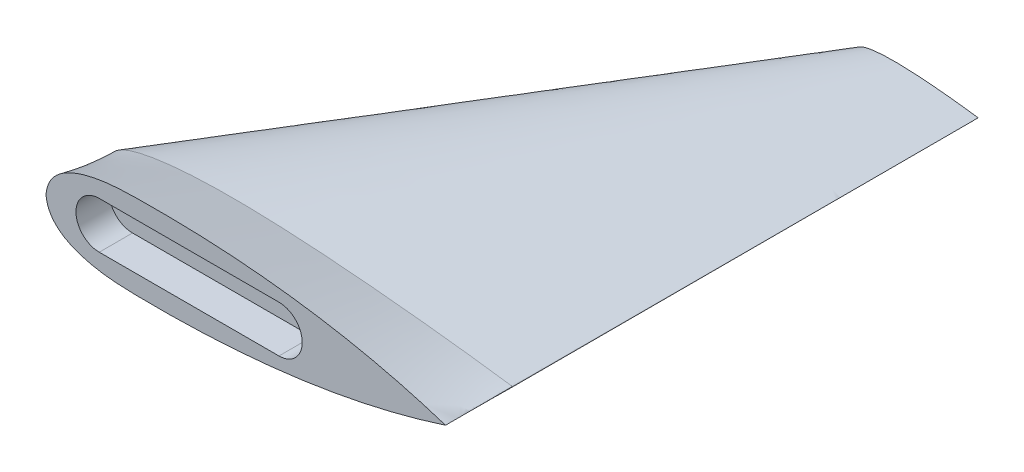
from build123d import *

# Parameters (mm, degrees)
CUT_EXTRUDE1_DEPTH = 5


with BuildPart() as part:
    # Sketch3 → Loft1 section 0
    with BuildSketch(Plane.XY.offset(70)):
        with BuildLine():
            add(Edge.make_bspline(
                [(42.022876489, 0), (42.022876489, -0.025878497), (42.030292538, -0.078965607), (42.063554444, -0.155915402), (42.117908781, -0.22997435), (42.19269573, -0.301463886), (42.287673315, -0.37063511), (42.402703243, -0.437554112), (42.537617166, -0.502144861), (42.69217588, -0.564260941), (42.866072758, -0.623717465), (43.058936641, -0.68031524), (43.270343068, -0.733841033), (43.49981216, -0.784100531), (43.74682173, -0.830887268), (44.010800762, -0.874031015), (44.291140004, -0.913354711), (44.587187402, -0.948725601), (44.898254935, -0.980017341), (45.223617257, -1.007142862), (45.562516237, -1.030039418), (45.914162375, -1.048668566), (46.27773462, -1.06303447), (46.652384122, -1.073163985), (47.037236556, -1.079112462), (47.43139403, -1.080971986), (47.833935949, -1.078853752), (48.243922409, -1.07289628), (48.660396106, -1.063260995), (49.082385456, -1.050131052), (49.508904835, -1.033698226), (49.938957981, -1.01417393), (50.371540867, -0.99177977), (50.805643888, -0.966741353), (51.240253368, -0.93929129), (51.674354334, -0.909662993), (52.106933472, -0.878089086), (52.53698035, -0.844806242), (52.963490882, -0.81003717), (53.38546826, -0.774008998), (53.801928512, -0.736940084), (54.211897782, -0.699043587), (54.614419588, -0.660532173), (55.008552494, -0.621601817), (55.393377825, -0.582454731), (55.767995156, -0.543281249), (56.131530502, -0.504273993), (56.48313406, -0.465622723), (56.821984355, -0.427500623), (57.147291331, -0.390101403), (57.458294583, -0.353598981), (57.754267715, -0.318172697), (58.034518631, -0.283997105), (58.298393967, -0.25125135), (58.54527673, -0.220100521), (58.77459078, -0.190718852), (58.9857996, -0.163257461), (59.178410588, -0.137883615), (59.351975669, -0.114738335), (59.506082658, -0.093952342), (59.640393607, -0.075694011), (59.754528952, -0.059944097), (59.848410148, -0.047189767), (59.921315664, -0.036471248), (59.974295109, -0.030390073), (60.004730475, -0.023809382), (60.035948769, -0.024404103), (60.035948769, 0.024404103), (60.004730475, 0.023809382), (59.974295109, 0.030390073), (59.921315664, 0.036471248), (59.848410148, 0.047189767), (59.754528952, 0.059944097), (59.640393607, 0.075694011), (59.506082658, 0.093952342), (59.351975669, 0.114738335), (59.178410588, 0.137883615), (58.9857996, 0.163257461), (58.77459078, 0.190718852), (58.54527673, 0.220100521), (58.298393967, 0.25125135), (58.034518631, 0.283997105), (57.754267715, 0.318172697), (57.458294583, 0.353598981), (57.147291331, 0.390101403), (56.821984355, 0.427500623), (56.48313406, 0.465622723), (56.131530502, 0.504273993), (55.767995156, 0.543281249), (55.393377825, 0.582454731), (55.008552494, 0.621601817), (54.614419588, 0.660532173), (54.211897782, 0.699043587), (53.801928512, 0.736940084), (53.38546826, 0.774008998), (52.963490882, 0.81003717), (52.53698035, 0.844806242), (52.106933472, 0.878089086), (51.674354334, 0.909662993), (51.240253368, 0.93929129), (50.805643888, 0.966741353), (50.371540867, 0.99177977), (49.938957981, 1.01417393), (49.508904835, 1.033698226), (49.082385456, 1.050131052), (48.660396106, 1.063260995), (48.243922409, 1.07289628), (47.833935949, 1.078853752), (47.43139403, 1.080971986), (47.037236556, 1.079112462), (46.652384122, 1.073163985), (46.27773462, 1.06303447), (45.914162375, 1.048668566), (45.562516237, 1.030039418), (45.223617257, 1.007142862), (44.898254935, 0.980017341), (44.587187402, 0.948725601), (44.291140004, 0.913354711), (44.010800762, 0.874031015), (43.74682173, 0.830887268), (43.49981216, 0.784100531), (43.270343068, 0.733841033), (43.058936641, 0.68031524), (42.866072758, 0.623717465), (42.69217588, 0.564260941), (42.537617166, 0.502144861), (42.402703243, 0.437554112), (42.287673315, 0.37063511), (42.19269573, 0.301463886), (42.117908781, 0.22997435), (42.063554444, 0.155915402), (42.030292538, 0.078965607), (42.022876489, 0.025878497), (42.022876489, 0)],
                knots=[0, 0, 0, 0, 0.002106168, 0.00432059, 0.006772783, 0.009556697, 0.012734041, 0.016342888, 0.020405604, 0.024934102, 0.029933071, 0.035402241, 0.04133743, 0.04773159, 0.054575389, 0.061857405, 0.069564571, 0.077682311, 0.086194684, 0.095084441, 0.104333244, 0.1139217, 0.123829339, 0.134034708, 0.144515531, 0.155248716, 0.166210356, 0.177375783, 0.188719821, 0.200216647, 0.211839951, 0.223562989, 0.235358653, 0.247199625, 0.259058395, 0.270907226, 0.282718457, 0.294464514, 0.306117689, 0.317650771, 0.329036618, 0.34024851, 0.351259999, 0.362045273, 0.372578891, 0.382836142, 0.392792739, 0.40242532, 0.411711115, 0.420628244, 0.429155673, 0.437273179, 0.444961561, 0.452202575, 0.458979063, 0.465274876, 0.471074963, 0.476365569, 0.481133961, 0.485368768, 0.489059784, 0.492198148, 0.494776266, 0.49678801, 0.498228425, 0.499094073, 0.499382862, 0.500617138, 0.500905927, 0.501771575, 0.50321199, 0.505223734, 0.507801852, 0.510940216, 0.514631232, 0.518866039, 0.523634431, 0.528925037, 0.534725124, 0.541020937, 0.547797425, 0.555038439, 0.562726821, 0.570844327, 0.579371756, 0.588288885, 0.59757468, 0.607207261, 0.617163858, 0.627421109, 0.637954727, 0.648740001, 0.65975149, 0.670963382, 0.682349229, 0.693882311, 0.705535486, 0.717281543, 0.729092774, 0.740941605, 0.752800375, 0.764641347, 0.776437011, 0.788160049, 0.799783353, 0.811280179, 0.822624217, 0.833789644, 0.844751284, 0.855484469, 0.865965292, 0.876170661, 0.8860783, 0.895666756, 0.904915559, 0.913805316, 0.922317689, 0.930435429, 0.938142595, 0.945424611, 0.95226841, 0.95866257, 0.964597759, 0.970066929, 0.975065898, 0.979594396, 0.983657112, 0.987265959, 0.990443303, 0.993227217, 0.99567941, 0.997893832, 1, 1, 1, 1], degree=3))
        make_face()
    # Sketch2 → Loft1 section 1
    with BuildSketch(Plane.XY):
        with BuildLine():
            add(Edge.make_bspline(
                [(0, 0), (0, -0.086261656), (0.024720162, -0.263218691), (0.135593184, -0.519718008), (0.316774305, -0.766581167), (0.566064137, -1.00487962), (0.882656087, -1.235450366), (1.26608918, -1.458513708), (1.715802257, -1.673816202), (2.23099797, -1.880869804), (2.81065423, -2.079058216), (3.453533838, -2.267717466), (4.158221929, -2.446136776), (4.923118902, -2.613668437), (5.746484136, -2.769624226), (6.626414244, -2.913436716), (7.560878382, -3.044515703), (8.547703041, -3.162418671), (9.584594818, -3.266724471), (10.669135892, -3.357142873), (11.798799161, -3.433464726), (12.970952952, -3.495561888), (14.182860437, -3.543448233), (15.43169211, -3.577213282), (16.714533557, -3.597041539), (18.028391802, -3.603239953), (19.370198199, -3.596179173), (20.736819734, -3.576320934), (22.125065389, -3.544203316), (23.531696556, -3.50043684), (24.953427821, -3.445660752), (26.386938306, -3.380579767), (27.82888126, -3.305932568), (29.27589133, -3.222471175), (30.724589596, -3.130970966), (32.171592815, -3.032209976), (33.613523275, -2.926963621), (35.04701287, -2.816020806), (36.468714641, -2.700123901), (37.875305901, -2.580029992), (39.263506742, -2.456466948), (40.630070975, -2.330145291), (41.971810329, -2.201773909), (43.285586683, -2.072006057), (44.568337784, -1.94151577), (45.817062224, -1.810937497), (47.028846709, -1.680913309), (48.20085857, -1.552075743), (49.330359552, -1.425002076), (50.414716139, -1.300338011), (51.451393648, -1.17866327), (52.437970753, -1.060575655), (53.372140472, -0.946657018), (54.251724925, -0.837504499), (55.07466747, -0.733668403), (55.839047636, -0.635729508), (56.543077037, -0.544191538), (57.185113664, -0.459612051), (57.763663931, -0.382461118), (58.277353896, -0.313174474), (58.72505706, -0.252313371), (59.105508208, -0.199813656), (59.418445528, -0.157299223), (59.661463916, -0.121570828), (59.838062067, -0.101300242), (59.939513285, -0.079364607), (60.043574265, -0.081347009), (60.043574265, 0.081347009), (59.939513285, 0.079364607), (59.838062067, 0.101300242), (59.661463916, 0.121570828), (59.418445528, 0.157299223), (59.105508208, 0.199813656), (58.72505706, 0.252313371), (58.277353896, 0.313174474), (57.763663931, 0.382461118), (57.185113664, 0.459612051), (56.543077037, 0.544191538), (55.839047636, 0.635729508), (55.07466747, 0.733668403), (54.251724925, 0.837504499), (53.372140472, 0.946657018), (52.437970753, 1.060575655), (51.451393648, 1.17866327), (50.414716139, 1.300338011), (49.330359552, 1.425002076), (48.20085857, 1.552075743), (47.028846709, 1.680913309), (45.817062224, 1.810937497), (44.568337784, 1.94151577), (43.285586683, 2.072006057), (41.971810329, 2.201773909), (40.630070975, 2.330145291), (39.263506742, 2.456466948), (37.875305901, 2.580029992), (36.468714641, 2.700123901), (35.04701287, 2.816020806), (33.613523275, 2.926963621), (32.171592815, 3.032209976), (30.724589596, 3.130970966), (29.27589133, 3.222471175), (27.82888126, 3.305932568), (26.386938306, 3.380579767), (24.953427821, 3.445660752), (23.531696556, 3.50043684), (22.125065389, 3.544203316), (20.736819734, 3.576320934), (19.370198199, 3.596179173), (18.028391802, 3.603239953), (16.714533557, 3.597041539), (15.43169211, 3.577213282), (14.182860437, 3.543448233), (12.970952952, 3.495561888), (11.798799161, 3.433464726), (10.669135892, 3.357142873), (9.584594818, 3.266724471), (8.547703041, 3.162418671), (7.560878382, 3.044515703), (6.626414244, 2.913436716), (5.746484136, 2.769624226), (4.923118902, 2.613668437), (4.158221929, 2.446136776), (3.453533838, 2.267717466), (2.81065423, 2.079058216), (2.23099797, 1.880869804), (1.715802257, 1.673816202), (1.26608918, 1.458513708), (0.882656087, 1.235450366), (0.566064137, 1.00487962), (0.316774305, 0.766581167), (0.135593184, 0.519718008), (0.024720162, 0.263218691), (0, 0.086261656), (0, 0)],
                knots=[0, 0, 0, 0, 0.002106168, 0.00432059, 0.006772783, 0.009556697, 0.012734041, 0.016342888, 0.020405604, 0.024934102, 0.029933071, 0.035402241, 0.04133743, 0.04773159, 0.054575389, 0.061857405, 0.069564571, 0.077682311, 0.086194684, 0.095084441, 0.104333244, 0.1139217, 0.123829339, 0.134034708, 0.144515531, 0.155248716, 0.166210356, 0.177375783, 0.188719821, 0.200216647, 0.211839951, 0.223562989, 0.235358653, 0.247199625, 0.259058395, 0.270907226, 0.282718457, 0.294464514, 0.306117689, 0.317650771, 0.329036618, 0.34024851, 0.351259999, 0.362045273, 0.372578891, 0.382836142, 0.392792739, 0.40242532, 0.411711115, 0.420628244, 0.429155673, 0.437273179, 0.444961561, 0.452202575, 0.458979063, 0.465274876, 0.471074963, 0.476365569, 0.481133961, 0.485368768, 0.489059784, 0.492198148, 0.494776266, 0.49678801, 0.498228425, 0.499094073, 0.499382862, 0.500617138, 0.500905927, 0.501771575, 0.50321199, 0.505223734, 0.507801852, 0.510940216, 0.514631232, 0.518866039, 0.523634431, 0.528925037, 0.534725124, 0.541020937, 0.547797425, 0.555038439, 0.562726821, 0.570844327, 0.579371756, 0.588288885, 0.59757468, 0.607207261, 0.617163858, 0.627421109, 0.637954727, 0.648740001, 0.65975149, 0.670963382, 0.682349229, 0.693882311, 0.705535486, 0.717281543, 0.729092774, 0.740941605, 0.752800375, 0.764641347, 0.776437011, 0.788160049, 0.799783353, 0.811280179, 0.822624217, 0.833789644, 0.844751284, 0.855484469, 0.865965292, 0.876170661, 0.8860783, 0.895666756, 0.904915559, 0.913805316, 0.922317689, 0.930435429, 0.938142595, 0.945424611, 0.95226841, 0.95866257, 0.964597759, 0.970066929, 0.975065898, 0.979594396, 0.983657112, 0.987265959, 0.990443303, 0.993227217, 0.99567941, 0.997893832, 1, 1, 1, 1], degree=3))
        make_face()
    loft()

    # Sketch8 → Loft2 section 0
    with BuildSketch(Plane(origin=(0, 0, -10), x_dir=(-1, 0, 0), z_dir=(0, 0, -1))):
        with BuildLine():
            add(Edge.make_bspline(
                [(-60.032680699, 0), (-45.229186862, 4.822427248), (-26.687327325, 6.871056485), (-5.794980295, 6.092943746), (-0.269324366, 3.253888107), (0, 0)],
                knots=[0, 0, 0, 0, 0.73900426, 0.864029196, 1, 1, 1, 1], degree=3))
            add(Edge.make_bspline(
                [(-60.032680699, 0), (-45.229186862, -4.822427248), (-26.687327325, -6.871056485), (-5.794980295, -6.092943746), (-0.269324366, -3.253888107), (0, 0)],
                knots=[0, 0, 0, 0, 0.73900426, 0.864029196, 1, 1, 1, 1], degree=3))
        make_face()
    # Sketch2_3 → Loft2 section 1
    with BuildSketch(Plane.XY):
        with BuildLine():
            add(Edge.make_bspline(
                [(0, 0), (0, -0.086261656), (0.024720162, -0.263218691), (0.135593184, -0.519718008), (0.316774305, -0.766581167), (0.566064137, -1.00487962), (0.882656087, -1.235450366), (1.26608918, -1.458513708), (1.715802257, -1.673816202), (2.23099797, -1.880869804), (2.81065423, -2.079058216), (3.453533838, -2.267717466), (4.158221929, -2.446136776), (4.923118902, -2.613668437), (5.746484136, -2.769624226), (6.626414244, -2.913436716), (7.560878382, -3.044515703), (8.547703041, -3.162418671), (9.584594818, -3.266724471), (10.669135892, -3.357142873), (11.798799161, -3.433464726), (12.970952952, -3.495561888), (14.182860437, -3.543448233), (15.43169211, -3.577213282), (16.714533557, -3.597041539), (18.028391802, -3.603239953), (19.370198199, -3.596179173), (20.736819734, -3.576320934), (22.125065389, -3.544203316), (23.531696556, -3.50043684), (24.953427821, -3.445660752), (26.386938306, -3.380579767), (27.82888126, -3.305932568), (29.27589133, -3.222471175), (30.724589596, -3.130970966), (32.171592815, -3.032209976), (33.613523275, -2.926963621), (35.04701287, -2.816020806), (36.468714641, -2.700123901), (37.875305901, -2.580029992), (39.263506742, -2.456466948), (40.630070975, -2.330145291), (41.971810329, -2.201773909), (43.285586683, -2.072006057), (44.568337784, -1.94151577), (45.817062224, -1.810937497), (47.028846709, -1.680913309), (48.20085857, -1.552075743), (49.330359552, -1.425002076), (50.414716139, -1.300338011), (51.451393648, -1.17866327), (52.437970753, -1.060575655), (53.372140472, -0.946657018), (54.251724925, -0.837504499), (55.07466747, -0.733668403), (55.839047636, -0.635729508), (56.543077037, -0.544191538), (57.185113664, -0.459612051), (57.763663931, -0.382461118), (58.277353896, -0.313174474), (58.72505706, -0.252313371), (59.105508208, -0.199813656), (59.418445528, -0.157299223), (59.661463916, -0.121570828), (59.838062067, -0.101300242), (59.939513285, -0.079364607), (60.043574265, -0.081347009), (60.043574265, 0.081347009), (59.939513285, 0.079364607), (59.838062067, 0.101300242), (59.661463916, 0.121570828), (59.418445528, 0.157299223), (59.105508208, 0.199813656), (58.72505706, 0.252313371), (58.277353896, 0.313174474), (57.763663931, 0.382461118), (57.185113664, 0.459612051), (56.543077037, 0.544191538), (55.839047636, 0.635729508), (55.07466747, 0.733668403), (54.251724925, 0.837504499), (53.372140472, 0.946657018), (52.437970753, 1.060575655), (51.451393648, 1.17866327), (50.414716139, 1.300338011), (49.330359552, 1.425002076), (48.20085857, 1.552075743), (47.028846709, 1.680913309), (45.817062224, 1.810937497), (44.568337784, 1.94151577), (43.285586683, 2.072006057), (41.971810329, 2.201773909), (40.630070975, 2.330145291), (39.263506742, 2.456466948), (37.875305901, 2.580029992), (36.468714641, 2.700123901), (35.04701287, 2.816020806), (33.613523275, 2.926963621), (32.171592815, 3.032209976), (30.724589596, 3.130970966), (29.27589133, 3.222471175), (27.82888126, 3.305932568), (26.386938306, 3.380579767), (24.953427821, 3.445660752), (23.531696556, 3.50043684), (22.125065389, 3.544203316), (20.736819734, 3.576320934), (19.370198199, 3.596179173), (18.028391802, 3.603239953), (16.714533557, 3.597041539), (15.43169211, 3.577213282), (14.182860437, 3.543448233), (12.970952952, 3.495561888), (11.798799161, 3.433464726), (10.669135892, 3.357142873), (9.584594818, 3.266724471), (8.547703041, 3.162418671), (7.560878382, 3.044515703), (6.626414244, 2.913436716), (5.746484136, 2.769624226), (4.923118902, 2.613668437), (4.158221929, 2.446136776), (3.453533838, 2.267717466), (2.81065423, 2.079058216), (2.23099797, 1.880869804), (1.715802257, 1.673816202), (1.26608918, 1.458513708), (0.882656087, 1.235450366), (0.566064137, 1.00487962), (0.316774305, 0.766581167), (0.135593184, 0.519718008), (0.024720162, 0.263218691), (0, 0.086261656), (0, 0)],
                knots=[0, 0, 0, 0, 0.002106168, 0.00432059, 0.006772783, 0.009556697, 0.012734041, 0.016342888, 0.020405604, 0.024934102, 0.029933071, 0.035402241, 0.04133743, 0.04773159, 0.054575389, 0.061857405, 0.069564571, 0.077682311, 0.086194684, 0.095084441, 0.104333244, 0.1139217, 0.123829339, 0.134034708, 0.144515531, 0.155248716, 0.166210356, 0.177375783, 0.188719821, 0.200216647, 0.211839951, 0.223562989, 0.235358653, 0.247199625, 0.259058395, 0.270907226, 0.282718457, 0.294464514, 0.306117689, 0.317650771, 0.329036618, 0.34024851, 0.351259999, 0.362045273, 0.372578891, 0.382836142, 0.392792739, 0.40242532, 0.411711115, 0.420628244, 0.429155673, 0.437273179, 0.444961561, 0.452202575, 0.458979063, 0.465274876, 0.471074963, 0.476365569, 0.481133961, 0.485368768, 0.489059784, 0.492198148, 0.494776266, 0.49678801, 0.498228425, 0.499094073, 0.499382862, 0.500617138, 0.500905927, 0.501771575, 0.50321199, 0.505223734, 0.507801852, 0.510940216, 0.514631232, 0.518866039, 0.523634431, 0.528925037, 0.534725124, 0.541020937, 0.547797425, 0.555038439, 0.562726821, 0.570844327, 0.579371756, 0.588288885, 0.59757468, 0.607207261, 0.617163858, 0.627421109, 0.637954727, 0.648740001, 0.65975149, 0.670963382, 0.682349229, 0.693882311, 0.705535486, 0.717281543, 0.729092774, 0.740941605, 0.752800375, 0.764641347, 0.776437011, 0.788160049, 0.799783353, 0.811280179, 0.822624217, 0.833789644, 0.844751284, 0.855484469, 0.865965292, 0.876170661, 0.8860783, 0.895666756, 0.904915559, 0.913805316, 0.922317689, 0.930435429, 0.938142595, 0.945424611, 0.95226841, 0.95866257, 0.964597759, 0.970066929, 0.975065898, 0.979594396, 0.983657112, 0.987265959, 0.990443303, 0.993227217, 0.99567941, 0.997893832, 1, 1, 1, 1], degree=3))
        make_face()
    loft()

    # Sketch9 → Cut-Extrude1 (cut)
    with BuildSketch(Plane(origin=(0, 0, -10), x_dir=(-1, 0, 0), z_dir=(0, 0, -1))):
        with BuildLine():
            Line((-35, 3.5), (-8, 3.5))
            ThreePointArc((-8, 3.5), (-4.5, 0), (-8, -3.5))
            Line((-8, -3.5), (-35, -3.5))
            ThreePointArc((-35, -3.5), (-38.5, 0), (-35, 3.5))
        make_face()
    extrude(amount=-CUT_EXTRUDE1_DEPTH, mode=Mode.SUBTRACT)


with BuildPart() as body_2:
    # Mirror1: mirrored copy
    add(part.part.mirror(Plane(origin=(0, 0, -10), x_dir=(1, 0, 0), z_dir=(0, 0, -1))))


solid = body_2.part
